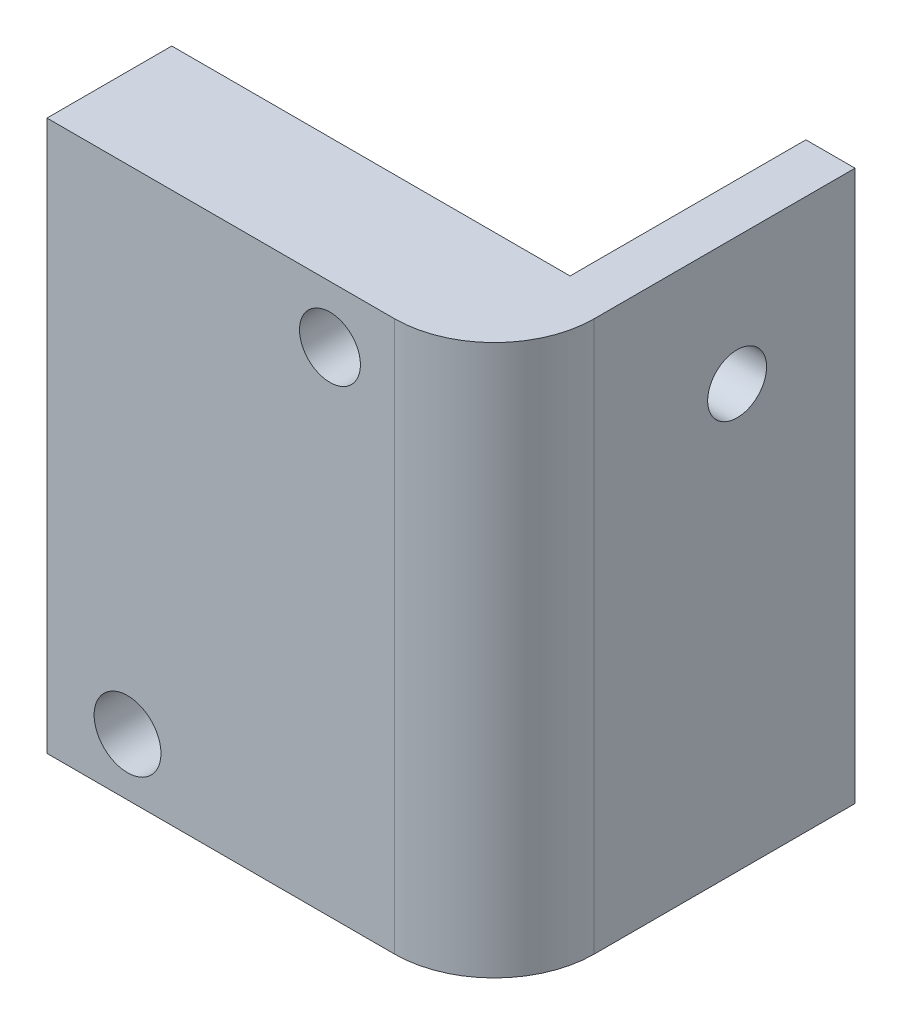
from build123d import *

# Parameters (mm, degrees)
BOSS_EXTRUDE1_DEPTH = 27.9999948
SKETCH2_R           = 1.5
CUT_EXTRUDE1_DEPTH  = 40.134145412
SKETCH3_R           = 1.55
SKETCH3_R_2         = 1.7
CUT_EXTRUDE2_DEPTH  = 41.485396183
FILLET1_R           = 5.08
SKETCH2_3_R         = 1.5
BOSS_EXTRUDE2_DEPTH = 3.048


with BuildPart() as part:
    # Sketch1 → Boss-Extrude1 (new body)
    with BuildSketch(Plane(origin=(0, 0, 0), x_dir=(1, 0, 0), z_dir=(0, 1, 0))):
        Polygon((0, 18.35), (0, 0), (-22.7671934, 0), (-22.7671934, 6.35), (-2.5, 6.35), (-2.5, 18.35), align=None)
    extrude(amount=BOSS_EXTRUDE1_DEPTH)

    # Sketch2 → Cut-Extrude1 (cut, through all)
    with BuildSketch(Plane.ZY.offset(2.5)):
        with Locations((-12.35, 21.4999951)):
            Circle(SKETCH2_R)
    extrude(amount=-CUT_EXTRUDE1_DEPTH, mode=Mode.SUBTRACT)

    # Sketch3 → Cut-Extrude2 (cut, through all)
    with BuildSketch(Plane.XY):
        with Locations((-8.368, 25.0999974)):
            Circle(SKETCH3_R)
        with Locations((-18.668, 2.8999974)):
            Circle(SKETCH3_R_2)
    extrude(amount=-CUT_EXTRUDE2_DEPTH, mode=Mode.SUBTRACT)

    # Fillet1
    fillet1_edges = [part.edges().sort_by_distance(p)[0] for p in [
        (0, 13.9999974, 0),
    ]]
    fillet(fillet1_edges, radius=FILLET1_R)

    # Sketch2_3 → Boss-Extrude2 (add)
    with BuildSketch(Plane.ZY.offset(2.5)):
        with Locations((-12.35, 6.4999997)):
            Circle(SKETCH2_3_R)
    extrude(amount=BOSS_EXTRUDE2_DEPTH)


solid = part.part
